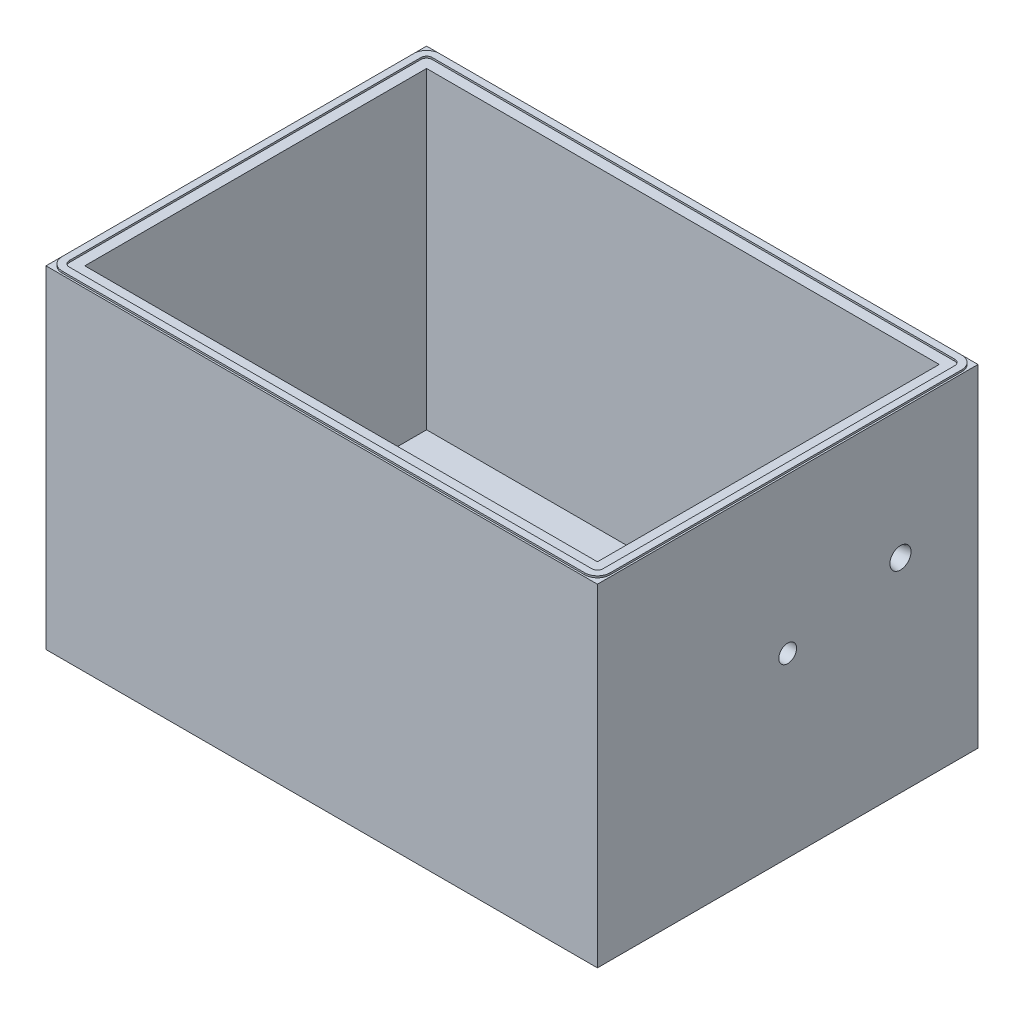
from build123d import *

# Parameters (mm, degrees)
SKETCH1_W           = 496.824
SKETCH1_H           = 342.9
BOSS_EXTRUDE1_DEPTH = 17.4625
BOSS_EXTRUDE2_START = -17.4625
SKETCH2_W           = 496.824
SKETCH2_H           = 342.9
SKETCH2_W_2         = 461.899
SKETCH2_H_2         = 307.975
BOSS_EXTRUDE2_DEPTH = 301
SKETCH11_W          = 461.899
SKETCH11_H          = 307.975
CUT_EXTRUDE2_DEPTH  = 1.5875
SKETCH30_R          = 9.525
CUT_EXTRUDE4_DEPTH  = 17.4625
CUT_EXTRUDE4_TAPER  = 10.304
SKETCH34_W          = 496.824
SKETCH34_H          = 342.9
CUT_EXTRUDE5_DEPTH  = 1.5875
CUT_EXTRUDE6_REACH  = 498.824
SKETCH35_R          = 8.001


with BuildPart() as part:
    # Sketch1 → Boss-Extrude1 (new body)
    with BuildSketch(Plane(origin=(0, 0, 0), x_dir=(1, 0, 0), z_dir=(0, 1, 0))):
        Rectangle(SKETCH1_W, SKETCH1_H)
    extrude(amount=BOSS_EXTRUDE1_DEPTH)

    # Sketch2 → Boss-Extrude2 (add)
    with BuildSketch(Plane(origin=(0, 17.4625, 0), x_dir=(1, 0, 0), z_dir=(0, 1, 0)).offset(BOSS_EXTRUDE2_START)):
        Rectangle(SKETCH2_W, SKETCH2_H)
        Rectangle(SKETCH2_W_2, SKETCH2_H_2, mode=Mode.SUBTRACT)
    extrude(amount=BOSS_EXTRUDE2_DEPTH)

    # Sketch11 → Cut-Extrude2 (cut)
    with BuildSketch(Plane(origin=(0, 301, 0), x_dir=(1, 0, 0), z_dir=(0, 1, 0))):
        with BuildLine():
            Line((235.3945, 163.5125), (-235.3945, 163.5125))
            ThreePointArc((-235.3945, 163.5125), (-238.986602448, 162.024602448), (-240.4745, 158.4325))
            Line((-240.4745, 158.4325), (-240.4745, -158.4325))
            ThreePointArc((-240.4745, -158.4325), (-238.986602448, -162.024602448), (-235.3945, -163.5125))
            Line((-235.3945, -163.5125), (235.3945, -163.5125))
            ThreePointArc((235.3945, -163.5125), (238.986602448, -162.024602448), (240.4745, -158.4325))
            Line((240.4745, -158.4325), (240.4745, 158.4325))
            ThreePointArc((240.4745, 158.4325), (238.986602448, 162.024602448), (235.3945, 163.5125))
        make_face()
        Rectangle(SKETCH11_W, SKETCH11_H, mode=Mode.SUBTRACT)
    extrude(amount=-CUT_EXTRUDE2_DEPTH, mode=Mode.SUBTRACT)

    # Sketch30 → Cut-Extrude4 (cut)
    with BuildSketch(Plane(origin=(248.412, 0, 0), x_dir=(0, 0, -1), z_dir=(1, 0, 0))):
        with Locations((101.6, 183.525)):
            Circle(SKETCH30_R)
    extrude(amount=-CUT_EXTRUDE4_DEPTH, taper=CUT_EXTRUDE4_TAPER, mode=Mode.SUBTRACT)

    # Sketch34 → Cut-Extrude5 (cut)
    with BuildSketch(Plane(origin=(0, 301, 0), x_dir=(1, 0, 0), z_dir=(0, 1, 0))):
        Rectangle(SKETCH34_W, SKETCH34_H)
        with BuildLine():
            Line((-235.3945, -169.8625), (235.3945, -169.8625))
            ThreePointArc((235.3945, -169.8625), (243.476730509, -166.514730509), (246.8245, -158.4325))
            Line((246.8245, -158.4325), (246.8245, 158.4325))
            ThreePointArc((246.8245, 158.4325), (243.476730509, 166.514730509), (235.3945, 169.8625))
            Line((235.3945, 169.8625), (-235.3945, 169.8625))
            ThreePointArc((-235.3945, 169.8625), (-243.476730509, 166.514730509), (-246.8245, 158.4325))
            Line((-246.8245, 158.4325), (-246.8245, -158.4325))
            ThreePointArc((-246.8245, -158.4325), (-243.476730509, -166.514730509), (-235.3945, -169.8625))
        make_face(mode=Mode.SUBTRACT)
    extrude(amount=-CUT_EXTRUDE5_DEPTH, mode=Mode.SUBTRACT)

    # Sketch35 → Cut-Extrude6 (cut, up to next)
    with BuildSketch(Plane(origin=(248.412, 0, 0), x_dir=(0, 0, -1), z_dir=(1, 0, 0)), mode=Mode.PRIVATE) as cut_extrude6_sk1:
        with Locations((0, 159.7125)):
            Circle(SKETCH35_R)
    cut_extrude6_tool1 = extrude(cut_extrude6_sk1.sketch, amount=-CUT_EXTRUDE6_REACH, mode=Mode.PRIVATE) & part.part
    add(cut_extrude6_tool1.solids().sort_by_distance((248.412, 159.7125, 0))[0], mode=Mode.SUBTRACT)


solid = part.part
